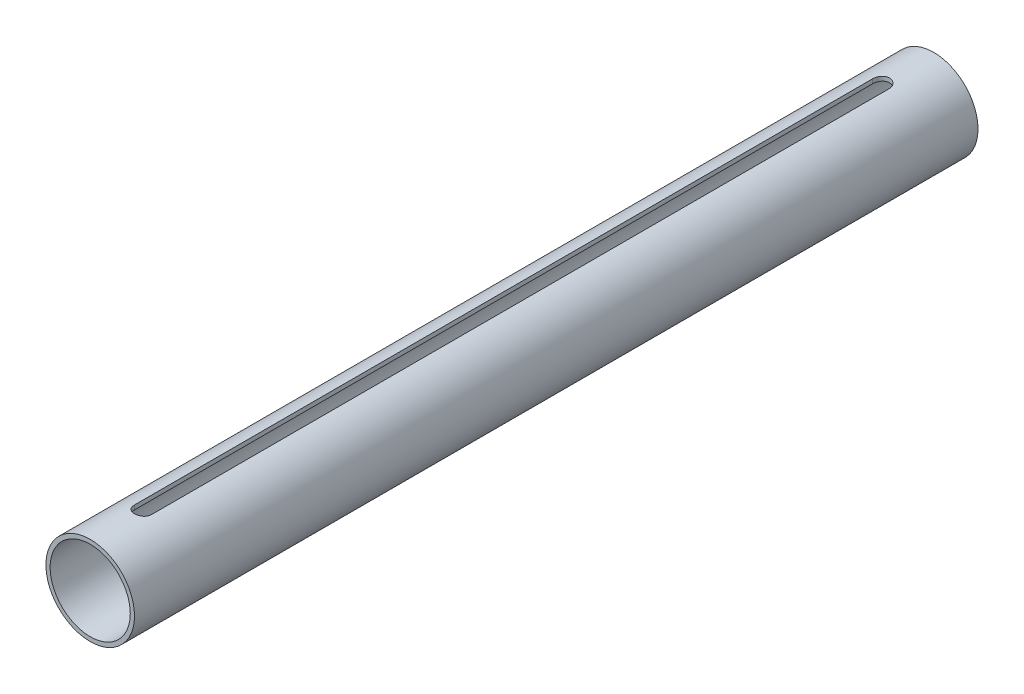
from build123d import *

# Parameters (mm, degrees)
SKETCH1_R           = 21
SKETCH1_R_2         = 19
BOSS_EXTRUDE1_DEPTH = 200
CUT_EXTRUDE1_REACH  = 45


with BuildPart() as part:
    # Sketch1 → Boss-Extrude1 (new body, symmetric)
    with BuildSketch(Plane.XY):
        Circle(SKETCH1_R)
        Circle(SKETCH1_R_2, mode=Mode.SUBTRACT)
    extrude(amount=BOSS_EXTRUDE1_DEPTH, both=True)

    # Sketch2 → Cut-Extrude1 (cut, up to next)
    with BuildSketch(Plane(origin=(0, 22, 0), x_dir=(1, 0, 0), z_dir=(0, 1, 0)), mode=Mode.PRIVATE) as cut_extrude1_sk1:
        with BuildLine():
            Line((-4, -175), (-4, 175))
            ThreePointArc((-4, 175), (0, 179), (4, 175))
            Line((4, 175), (4, -175))
            ThreePointArc((4, -175), (0, -179), (-4, -175))
        make_face()
    cut_extrude1_tool1 = extrude(cut_extrude1_sk1.sketch, amount=-CUT_EXTRUDE1_REACH, mode=Mode.PRIVATE) & part.part
    add(cut_extrude1_tool1.solids().sort_by_distance((0, 22, 0))[0], mode=Mode.SUBTRACT)


solid = part.part
